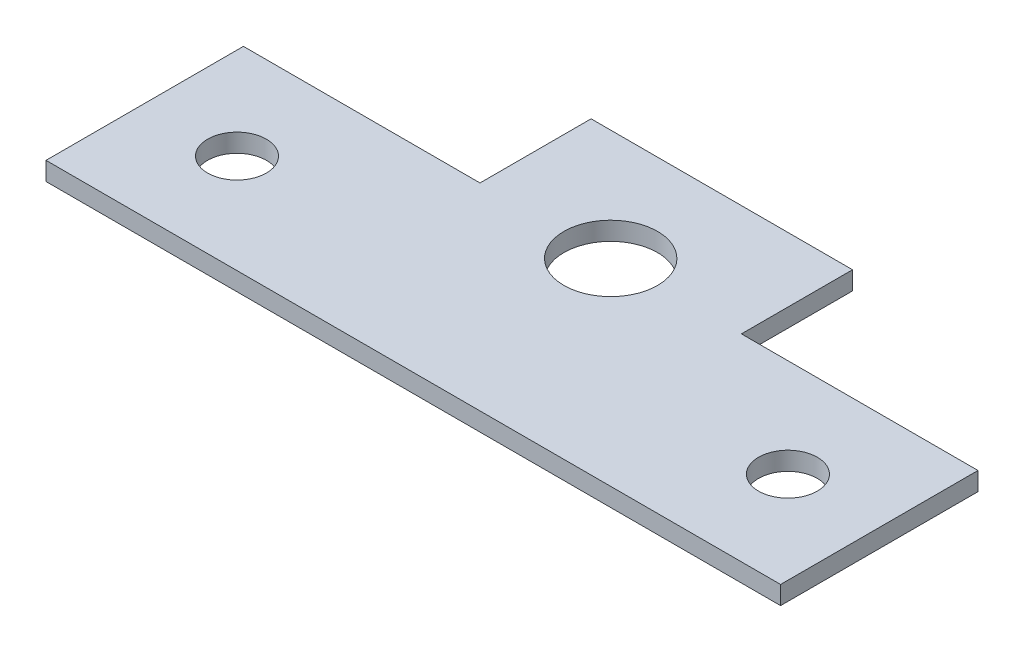
from build123d import *

# Parameters (mm, degrees)
SKETCH_1_W          = 40
SKETCH_1_H          = 16.8
EXTRUDE_1_DEPTH     = 1
SKETCH_3_R          = 1.6
SKETCH_3_R_2        = 2.55
SKETCH_3_W          = 12.882492612
SKETCH_3_H          = 6.05
CUT_EXTRUDE_1_DEPTH = 2


with BuildPart() as part:
    # Эскиз1 → Бобышка-Вытянуть1 (new body)
    with BuildSketch(Plane(origin=(0, 0, 0), x_dir=(1, 0, 0), z_dir=(0, 1, 0))):
        Rectangle(SKETCH_1_W, SKETCH_1_H)
    extrude(amount=EXTRUDE_1_DEPTH)

    # Эскиз3 → Вырез-Вытянуть1 (cut, through all)
    with BuildSketch(Plane(origin=(0, 1, 0), x_dir=(1, 0, 0), z_dir=(0, 1, 0))):
        with Locations((-15, -3)):
            Circle(SKETCH_3_R)
        with Locations((15, -3)):
            Circle(SKETCH_3_R)
        with Locations((0, 2.35)):
            Circle(SKETCH_3_R_2)
        with Locations((13.558753694, 5.375)):
            Rectangle(SKETCH_3_W, SKETCH_3_H)
        with Locations((-13.558753694, 5.375)):
            Rectangle(SKETCH_3_W, SKETCH_3_H)
    extrude(amount=-CUT_EXTRUDE_1_DEPTH, mode=Mode.SUBTRACT)


solid = part.part
